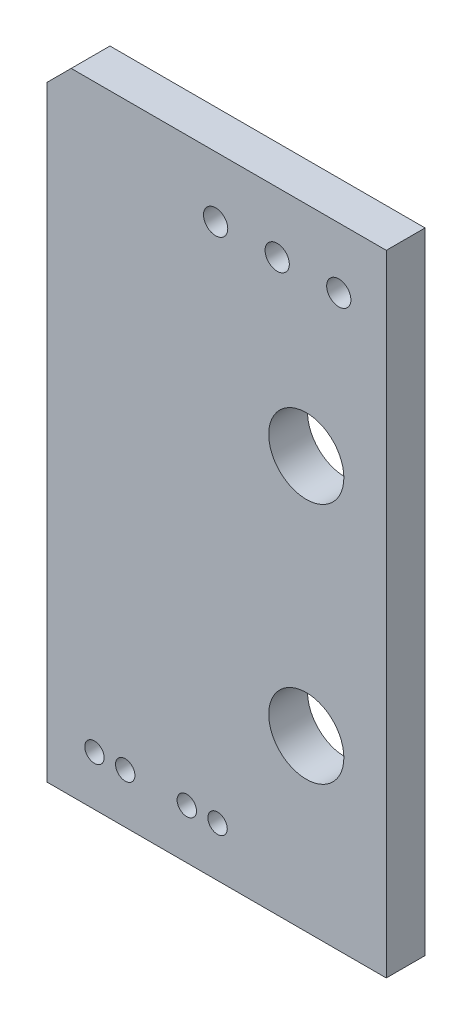
from build123d import *

# Parameters (mm, degrees)
SKETCH1_W           = 14
SKETCH1_H           = 26
SKETCH1_R           = 0.5
SKETCH1_R_2         = 0.4
SKETCH1_R_3         = 1.55
BOSS_EXTRUDE1_DEPTH = 1.6
CHAMFER1_SIZE       = 1


with BuildPart() as part:
    # Sketch1 → Boss-Extrude1 (new body)
    with BuildSketch(Plane.XY):
        with Locations((0, 13)):
            Rectangle(SKETCH1_W, SKETCH1_H)
        with Locations((-0.04, 23.5)):
            Circle(SKETCH1_R, mode=Mode.SUBTRACT)
        with Locations((2.5, 23.5)):
            Circle(SKETCH1_R, mode=Mode.SUBTRACT)
        with Locations((5.04, 23.5)):
            Circle(SKETCH1_R, mode=Mode.SUBTRACT)
        with Locations((-5.04, 2.05)):
            Circle(SKETCH1_R_2, mode=Mode.SUBTRACT)
        with Locations((-3.77, 2.05)):
            Circle(SKETCH1_R_2, mode=Mode.SUBTRACT)
        with Locations((-1.23, 2.05)):
            Circle(SKETCH1_R_2, mode=Mode.SUBTRACT)
        with Locations((0.04, 2.05)):
            Circle(SKETCH1_R_2, mode=Mode.SUBTRACT)
        with Locations((3.7, 7)):
            Circle(SKETCH1_R_3, mode=Mode.SUBTRACT)
        with Locations((3.7, 17)):
            Circle(SKETCH1_R_3, mode=Mode.SUBTRACT)
    extrude(amount=BOSS_EXTRUDE1_DEPTH)

    # Chamfer1
    chamfer1_edges = [part.edges().sort_by_distance(p)[0] for p in [
        (-7, 26, 0.8),
    ]]
    chamfer(chamfer1_edges, length=CHAMFER1_SIZE)


solid = part.part
